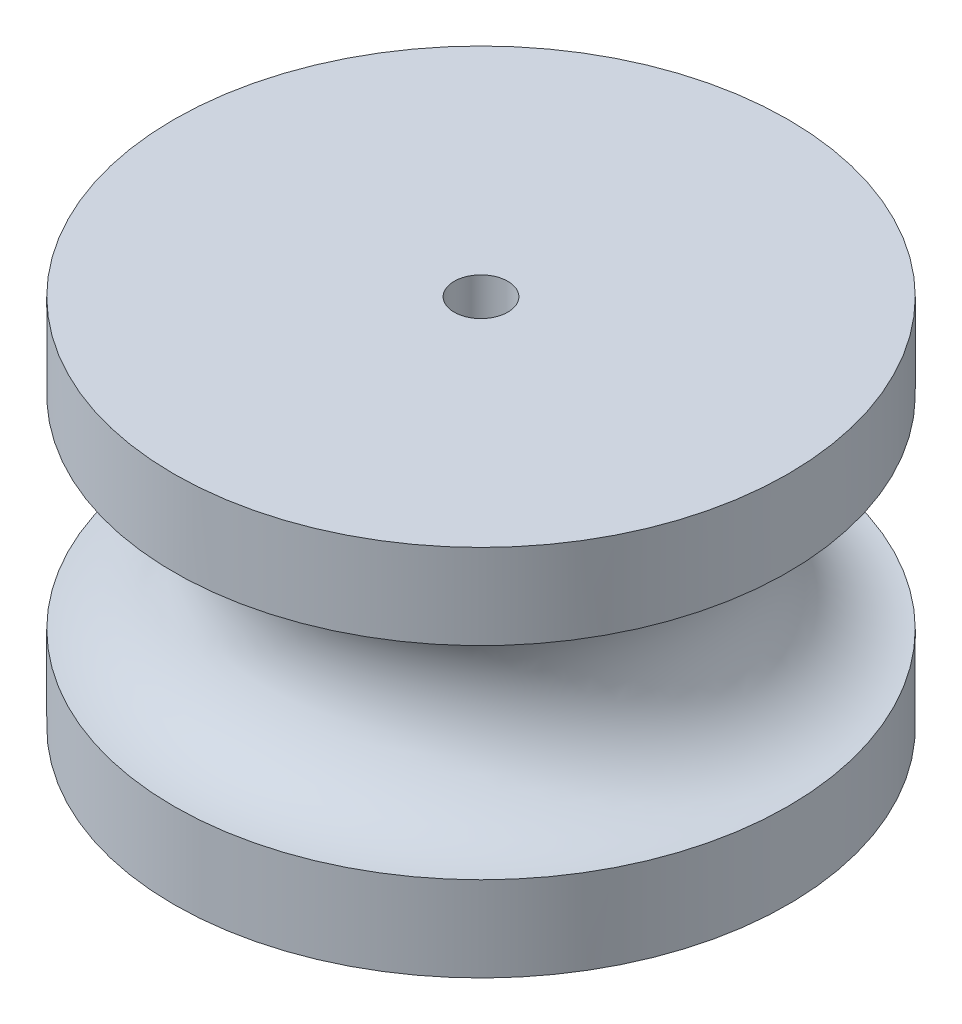
from build123d import *

# Parameters (mm, degrees)
SKETCH1_R           = 7
BOSS_EXTRUDE1_DEPTH = 6.5
SKETCH2_R           = 7
SKETCH2_R_2         = 0.611197666
BOSS_EXTRUDE2_DEPTH = 2
SKETCH3_R           = 2.310970428


with BuildPart() as part:
    # Sketch1 → Boss-Extrude1 (new body)
    with BuildSketch(Plane(origin=(0, 0, 0), x_dir=(1, 0, 0), z_dir=(0, 1, 0))):
        with Locations(Location((0, 0, 0), (0, 0, 270))):  # turned: the seam where the file's is
            Circle(SKETCH1_R)
        with BuildLine():
            Line((-1.88, 1.937937047), (-1.88, -1.937937047))
            ThreePointArc((-1.88, -1.937937047), (0, -2.7), (1.88, -1.937937047))
            Line((1.88, -1.937937047), (1.88, 1.937937047))
            ThreePointArc((1.88, 1.937937047), (0, 2.7), (-1.88, 1.937937047))
        make_face(mode=Mode.SUBTRACT)
    extrude(amount=BOSS_EXTRUDE1_DEPTH)

    # Sketch2 → Boss-Extrude2 (add)
    with BuildSketch(Plane(origin=(0, 6.5, 0), x_dir=(1, 0, 0), z_dir=(0, 1, 0))):
        with Locations(Location((0, 0, 0), (0, 0, 270))):  # turned: the seam where the file's is
            Circle(SKETCH2_R)
        with Locations(Location((0, 0, 0), (0, 0, 270))):  # turned: the seam where the file's is
            Circle(SKETCH2_R_2, mode=Mode.SUBTRACT)
    extrude(amount=BOSS_EXTRUDE2_DEPTH)

    # Sketch3 → Cut-Revolve1 (revolve, cut)
    with BuildSketch(Plane(origin=(0, 0, 0), x_dir=(0, 0, -1), z_dir=(1, 0, 0))):
        with Locations((-7, 4.25)):
            Circle(SKETCH3_R)
    revolve(axis=Axis((0, 0, 0), (0, 1, 0)), mode=Mode.SUBTRACT)


solid = part.part
